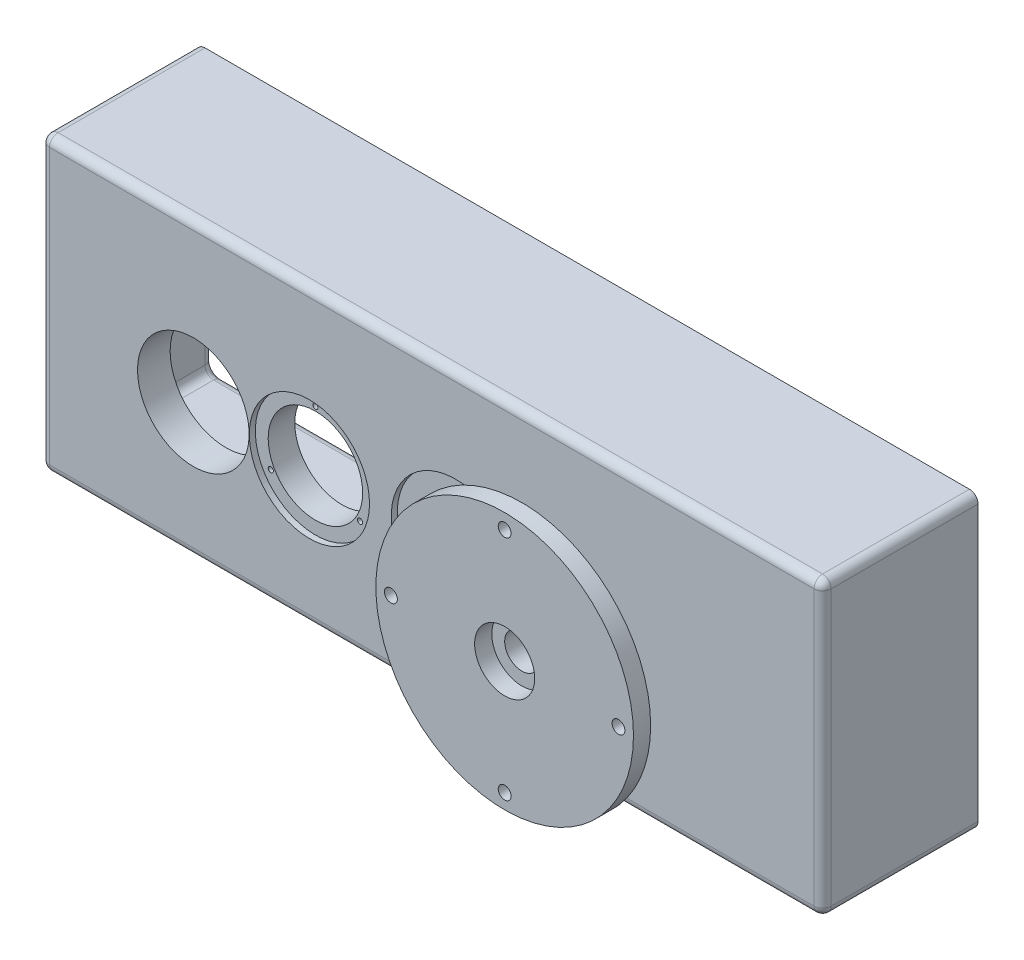
from build123d import *

# Parameters (mm, degrees)
SKETCH1_W           = 910.189861438
SKETCH1_H           = 340
BOSS_EXTRUDE1_DEPTH = 38
SKETCH2_R           = 65
SKETCH2_R_2         = 55
SKETCH2_R_3         = 45
SKETCH2_R_4         = 20
CUT_EXTRUDE1_DEPTH  = 39
SKETCH4_OUTSIDE_W   = 1106.662
SKETCH4_OUTSIDE_H   = 536.472
SKETCH4_OUTSIDE_R   = 30
SKETCH4_OUTSIDE_R_2 = 55
SKETCH4_OUTSIDE_R_3 = 65
SKETCH4_OUTSIDE_R_4 = 70
CUT_EXTRUDE2_DEPTH  = 11
SKETCH10_W          = 910.189861438
SKETCH10_H          = 340
SKETCH10_W_2        = 870.189861438
SKETCH10_H_2        = 302.19263839
BOSS_EXTRUDE2_DEPTH = 154
FILLET1_R           = 10
SKETCH11_R          = 35
SKETCH11_R_2        = 75
SKETCH11_R_3        = 70
CUT_EXTRUDE3_DEPTH  = 7
FILLET2_R           = 10
SKETCH12_R          = 3
CUT_EXTRUDE4_DEPTH  = 182
SKETCH15_R          = 35
SKETCH15_R_2        = 20
BOSS_EXTRUDE3_DEPTH = 60
SKETCH20_R          = 150
SKETCH20_R_2        = 35
BOSS_EXTRUDE4_DEPTH = 20
SKETCH21_R          = 7.5
CUT_EXTRUDE7_DEPTH  = 46


with BuildPart() as part:
    # Sketch1 → Boss-Extrude1 (new body)
    with BuildSketch(Plane.XY):
        with Locations((367.68214674, -113.598805358)):
            Rectangle(SKETCH1_W, SKETCH1_H)
    extrude(amount=BOSS_EXTRUDE1_DEPTH)

    # Sketch2 → Cut-Extrude1 (cut, through all)
    with BuildSketch(Plane(origin=(0, 0, 0), x_dir=(-1, 0, 0), z_dir=(0, 0, -1))):
        with Locations((-90.027216021, -126.638805358)):
            Circle(SKETCH2_R)
        with Locations((-225.197213686, -126.638805358)):
            Circle(SKETCH2_R_2)
        with Locations((-395.509950896, -126.638805358)):
            Circle(SKETCH2_R_3)
        with Locations((-532.589950896, -126.638805358)):
            Circle(SKETCH2_R_4)
    extrude(amount=-CUT_EXTRUDE1_DEPTH, mode=Mode.SUBTRACT)

    # Sketch4 outside → Cut-Extrude2 (cut)
    with BuildSketch(Plane(origin=(0, 0, 0), x_dir=(-1, 0, 0), z_dir=(0, 0, -1))):
        with Locations((-367.682, -113.599)):
            Rectangle(SKETCH4_OUTSIDE_W, SKETCH4_OUTSIDE_H)
        with Locations((-532.589950896, -126.638805358)):
            Circle(SKETCH4_OUTSIDE_R, mode=Mode.SUBTRACT)
        with Locations((-395.509950896, -126.638805358)):
            Circle(SKETCH4_OUTSIDE_R_2, mode=Mode.SUBTRACT)
        with Locations((-225.197213686, -126.638805358)):
            Circle(SKETCH4_OUTSIDE_R_3, mode=Mode.SUBTRACT)
        with Locations((-90.027216021, -126.638805358)):
            Circle(SKETCH4_OUTSIDE_R_4, mode=Mode.SUBTRACT)
    extrude(amount=-CUT_EXTRUDE2_DEPTH, mode=Mode.SUBTRACT)

    # Sketch10 → Boss-Extrude2 (add)
    with BuildSketch(Plane(origin=(0, 0, 11), x_dir=(-1, 0, 0), z_dir=(0, 0, -1))):
        with Locations((-367.68214674, -113.598805358)):
            Rectangle(SKETCH10_W, SKETCH10_H)
        with Locations((-367.68214674, -112.502486163)):
            Rectangle(SKETCH10_W_2, SKETCH10_H_2, mode=Mode.SUBTRACT)
    extrude(amount=BOSS_EXTRUDE2_DEPTH)

    # Fillet1
    fillet1_edges = [part.edges().sort_by_distance(p)[0] for p in [
        (822.777077459, -113.598805358, 38),
        (367.68214674, 56.401194642, 38),
        (-87.412783979, -113.598805358, 38),
        (-87.412783979, 56.401194642, -52.5),
        (822.777077459, 56.401194642, -52.5),
        (822.777077459, -283.598805358, -52.5),
        (-87.412783979, -283.598805358, -52.5),
        (367.68214674, -283.598805358, 38),
    ]]
    fillet(fillet1_edges, radius=FILLET1_R)

    # Sketch11 → Cut-Extrude3 (cut)
    with BuildSketch(Plane.XY.offset(38)):
        with Locations((532.589950896, -126.638805358)):
            Circle(SKETCH11_R)
        with Locations((395.509950896, -126.638805358)):
            Circle(SKETCH11_R_2)
        with Locations((225.197213686, -126.638805358)):
            Circle(SKETCH11_R_3)
    extrude(amount=-CUT_EXTRUDE3_DEPTH, mode=Mode.SUBTRACT)

    # Fillet2
    fillet2_edges = [part.edges().sort_by_distance(p)[0] for p in [
        (802.777077459, -112.502486163, 11),
        (367.68214674, -263.598805358, 11),
        (-67.412783979, -112.502486163, 11),
        (367.68214674, 38.593833032, 11),
        (802.777077459, -112.502486163, -143),
        (802.777077459, -263.598805358, -66),
        (367.68214674, -263.598805358, -143),
        (-67.412783979, -263.598805358, -66),
        (-67.412783979, -112.502486163, -143),
        (-67.412783979, 38.593833032, -66),
        (367.68214674, 38.593833032, -143),
        (802.777077459, 38.593833032, -66),
    ]]
    fillet(fillet2_edges, radius=FILLET2_R)

    # Sketch12 → Cut-Extrude4 (cut, through all)
    with BuildSketch(Plane.XY.offset(38)):
        with Locations((225.197213686, -66.638805358)):
            Circle(SKETCH12_R)
        with Locations((277.158737913, -156.638805358)):
            Circle(SKETCH12_R)
        with Locations((173.235689459, -156.638805358)):
            Circle(SKETCH12_R)
        with Locations((395.509950896, -66.638805358)):
            Circle(SKETCH12_R)
        with Locations((447.471475123, -156.638805358)):
            Circle(SKETCH12_R)
        with Locations((343.548426669, -156.638805358)):
            Circle(SKETCH12_R)
    extrude(amount=-CUT_EXTRUDE4_DEPTH, mode=Mode.SUBTRACT)


with BuildPart() as body_2:
    # Sketch15 → Boss-Extrude3 (new body)
    with BuildSketch(Plane.XY.offset(38)):
        with Locations((532.589950896, -126.638805358)):
            Circle(SKETCH15_R)
        with Locations((532.589950896, -126.638805358)):
            Circle(SKETCH15_R_2, mode=Mode.SUBTRACT)
    extrude(amount=BOSS_EXTRUDE3_DEPTH)


with BuildPart() as body_3:
    # Sketch20 → Boss-Extrude4 (new body)
    with BuildSketch(Plane.XY.offset(98)):
        with Locations((532.589950896, -126.638805358)):
            Circle(SKETCH20_R)
        with Locations((532.589950896, -126.638805358)):
            Circle(SKETCH20_R_2, mode=Mode.SUBTRACT)
    extrude(amount=BOSS_EXTRUDE4_DEPTH)

    # Sketch21 → Cut-Extrude7 (cut)
    with BuildSketch(Plane.XY.offset(118)):
        with Locations((532.589950896, 5.861194642)):
            Circle(SKETCH21_R)
        with Locations((665.089950896, -126.638805358)):
            Circle(SKETCH21_R)
        with Locations((532.589950896, -259.138805358)):
            Circle(SKETCH21_R)
        with Locations((400.089950896, -126.638805358)):
            Circle(SKETCH21_R)
    extrude(amount=-CUT_EXTRUDE7_DEPTH, mode=Mode.SUBTRACT)


solid = Compound([part.part, body_2.part, body_3.part])
